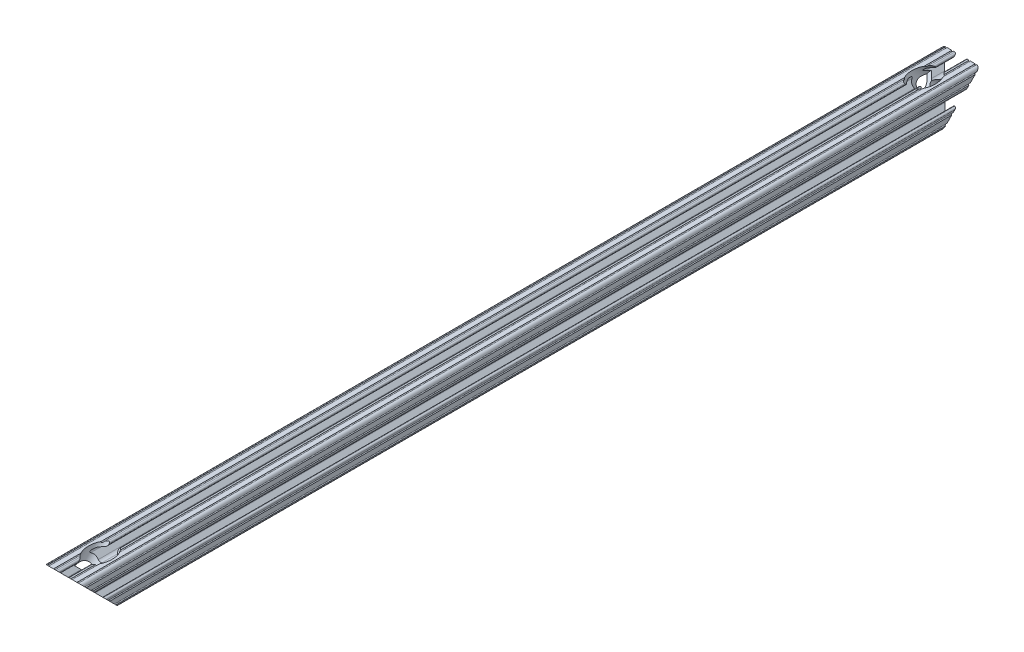
from build123d import *

# Parameters (mm, degrees)
SKETCH1_R               = 2.6035
BOSS_EXTRUDE1_DEPTH     = 304.8
CUT_EXTRUDE1_DEPTH      = 13.7
CUT_EXTRUDE1_DEPTH_BACK = 13.7


with BuildPart() as part:
    # Sketch1 → Boss-Extrude1 (new body, symmetric)
    with BuildSketch(Plane.XY):
        with BuildLine():
            Line((-7.179650497, -8.645192506), (-3.952270251, -5.423690499))
            ThreePointArc((-3.952270251, -5.423690499), (-2.922936451, -4.736929036), (-1.709253557, -4.4958))
            Line((-1.709253557, -4.4958), (1.709253557, -4.4958))
            ThreePointArc((1.709253557, -4.4958), (2.922936451, -4.736929036), (3.952270251, -5.423690499))
            Line((3.952270251, -5.423690499), (7.179650497, -8.645192506))
            ThreePointArc((7.179650497, -8.645192506), (7.41473083, -9.822813117), (6.416408329, -10.4902))
            Line((6.416408329, -10.4902), (4.287512407, -10.4902))
            ThreePointArc((4.287512407, -10.4902), (3.54574862, -10.79744862), (3.2385, -11.539212407))
            Line((3.2385, -11.539212407), (3.2385, -11.650987593))
            ThreePointArc((3.2385, -11.650987593), (3.54574862, -12.39275138), (4.287512407, -12.7))
            Line((4.287512407, -12.7), (5.317126718, -12.7))
            ThreePointArc((5.317126718, -12.7), (5.825126718, -12.192), (6.333126718, -12.7))
            Line((6.333126718, -12.7), (9.550443118, -12.7))
            ThreePointArc((9.550443118, -12.7), (10.058366869, -12.192000006), (10.566443095, -12.699847501))
            ThreePointArc((10.566443095, -12.699847501), (12.082537762, -12.08250727), (12.699846982, -10.566399977))
            ThreePointArc((12.699846982, -10.566399977), (12.192000006, -10.058323491), (12.7, -9.5504))
            Line((12.7, -9.5504), (12.7, -6.3330836))
            ThreePointArc((12.7, -6.3330836), (12.192, -5.8250836), (12.7, -5.3170836))
            Line((12.7, -5.3170836), (12.7, -4.287469289))
            ThreePointArc((12.7, -4.287469289), (12.39275138, -3.545705502), (11.650987593, -3.238456882))
            Line((11.650987593, -3.238456882), (11.539212407, -3.238456882))
            ThreePointArc((11.539212407, -3.238456882), (10.79744862, -3.545705502), (10.4902, -4.287469289))
            Line((10.4902, -4.287469289), (10.4902, -6.402089023))
            ThreePointArc((10.4902, -6.402089023), (9.856505071, -7.351067942), (8.737131347, -7.129408934))
            Line((8.737131347, -7.129408934), (5.441005833, -3.840816462))
            ThreePointArc((5.441005833, -3.840816462), (4.750877967, -2.809883091), (4.5085, -1.593185507))
            Line((4.5085, -1.593185507), (4.5085, 1.593185507))
            ThreePointArc((4.5085, 1.593185507), (4.750877967, 2.809883091), (5.441005833, 3.840816462))
            Line((5.441005833, 3.840816462), (8.737131347, 7.129408934))
            ThreePointArc((8.737131347, 7.129408934), (9.856505071, 7.351067942), (10.4902, 6.402089023))
            Line((10.4902, 6.402089023), (10.4902, 4.287469289))
            ThreePointArc((10.4902, 4.287469289), (10.79744862, 3.545705502), (11.539212407, 3.238456882))
            Line((11.539212407, 3.238456882), (11.650987593, 3.238456882))
            ThreePointArc((11.650987593, 3.238456882), (12.39275138, 3.545705502), (12.7, 4.287469289))
            Line((12.7, 4.287469289), (12.7, 5.3170836))
            ThreePointArc((12.7, 5.3170836), (12.192, 5.8250836), (12.7, 6.3330836))
            Line((12.7, 6.3330836), (12.7, 9.5504))
            ThreePointArc((12.7, 9.5504), (12.192000006, 10.058323491), (12.699846982, 10.566399977))
            ThreePointArc((12.699846982, 10.566399977), (12.082537762, 12.08250727), (10.566443095, 12.699847501))
            ThreePointArc((10.566443095, 12.699847501), (10.058366869, 12.192000006), (9.550443118, 12.7))
            Line((9.550443118, 12.7), (6.333126718, 12.7))
            ThreePointArc((6.333126718, 12.7), (5.825126718, 12.192), (5.317126718, 12.7))
            Line((5.317126718, 12.7), (4.287512407, 12.7))
            ThreePointArc((4.287512407, 12.7), (3.54574862, 12.39275138), (3.2385, 11.650987593))
            Line((3.2385, 11.650987593), (3.2385, 11.539212407))
            ThreePointArc((3.2385, 11.539212407), (3.54574862, 10.79744862), (4.287512407, 10.4902))
            Line((4.287512407, 10.4902), (6.476788598, 10.4902))
            ThreePointArc((6.476788598, 10.4902), (7.432222385, 9.85140422), (7.207036008, 8.724370562))
            Line((7.207036008, 8.724370562), (3.898272566, 5.423169045))
            ThreePointArc((3.898272566, 5.423169045), (2.869120213, 4.736787962), (1.655778399, 4.4958))
            Line((1.655778399, 4.4958), (-1.655778399, 4.4958))
            ThreePointArc((-1.655778399, 4.4958), (-2.869120213, 4.736787962), (-3.898272566, 5.423169045))
            Line((-3.898272566, 5.423169045), (-7.207036008, 8.724370562))
            ThreePointArc((-7.207036008, 8.724370562), (-7.432222385, 9.85140422), (-6.476788598, 10.4902))
            Line((-6.476788598, 10.4902), (-4.287512407, 10.4902))
            ThreePointArc((-4.287512407, 10.4902), (-3.54574862, 10.79744862), (-3.2385, 11.539212407))
            Line((-3.2385, 11.539212407), (-3.2385, 11.650987593))
            ThreePointArc((-3.2385, 11.650987593), (-3.54574862, 12.39275138), (-4.287512407, 12.7))
            Line((-4.287512407, 12.7), (-5.317126718, 12.7))
            ThreePointArc((-5.317126718, 12.7), (-5.825126718, 12.192), (-6.333126718, 12.7))
            Line((-6.333126718, 12.7), (-9.550443118, 12.7))
            ThreePointArc((-9.550443118, 12.7), (-10.058366869, 12.192000006), (-10.566443095, 12.699847501))
            ThreePointArc((-10.566443095, 12.699847501), (-12.082537762, 12.08250727), (-12.699846982, 10.566399977))
            ThreePointArc((-12.699846982, 10.566399977), (-12.192000006, 10.058323491), (-12.7, 9.5504))
            Line((-12.7, 9.5504), (-12.7, 6.3330836))
            ThreePointArc((-12.7, 6.3330836), (-12.192, 5.8250836), (-12.7, 5.3170836))
            Line((-12.7, 5.3170836), (-12.7, 4.287469289))
            ThreePointArc((-12.7, 4.287469289), (-12.39275138, 3.545705502), (-11.650987593, 3.238456882))
            Line((-11.650987593, 3.238456882), (-11.539212407, 3.238456882))
            ThreePointArc((-11.539212407, 3.238456882), (-10.79744862, 3.545705502), (-10.4902, 4.287469289))
            Line((-10.4902, 4.287469289), (-10.4902, 6.402089023))
            ThreePointArc((-10.4902, 6.402089023), (-9.856505071, 7.351067942), (-8.737131347, 7.129408934))
            Line((-8.737131347, 7.129408934), (-5.441005833, 3.840816462))
            ThreePointArc((-5.441005833, 3.840816462), (-4.750877967, 2.809883091), (-4.5085, 1.593185507))
            Line((-4.5085, 1.593185507), (-4.5085, -1.593185507))
            ThreePointArc((-4.5085, -1.593185507), (-4.750877967, -2.809883091), (-5.441005833, -3.840816462))
            Line((-5.441005833, -3.840816462), (-8.737131347, -7.129408934))
            ThreePointArc((-8.737131347, -7.129408934), (-9.856505071, -7.351067942), (-10.4902, -6.402089023))
            Line((-10.4902, -6.402089023), (-10.4902, -4.287469289))
            ThreePointArc((-10.4902, -4.287469289), (-10.79744862, -3.545705502), (-11.539212407, -3.238456882))
            Line((-11.539212407, -3.238456882), (-11.650987593, -3.238456882))
            ThreePointArc((-11.650987593, -3.238456882), (-12.39275138, -3.545705502), (-12.7, -4.287469289))
            Line((-12.7, -4.287469289), (-12.7, -5.3170836))
            ThreePointArc((-12.7, -5.3170836), (-12.192, -5.8250836), (-12.7, -6.3330836))
            Line((-12.7, -6.3330836), (-12.7, -9.5504))
            ThreePointArc((-12.7, -9.5504), (-12.192000006, -10.058323491), (-12.699846982, -10.566399977))
            ThreePointArc((-12.699846982, -10.566399977), (-12.082537762, -12.08250727), (-10.566443095, -12.699847501))
            ThreePointArc((-10.566443095, -12.699847501), (-10.058366869, -12.192000006), (-9.550443118, -12.7))
            Line((-9.550443118, -12.7), (-6.333126718, -12.7))
            ThreePointArc((-6.333126718, -12.7), (-5.825126718, -12.192), (-5.317126718, -12.7))
            Line((-5.317126718, -12.7), (-4.287512407, -12.7))
            ThreePointArc((-4.287512407, -12.7), (-3.54574862, -12.39275138), (-3.2385, -11.650987593))
            Line((-3.2385, -11.650987593), (-3.2385, -11.539212407))
            ThreePointArc((-3.2385, -11.539212407), (-3.54574862, -10.79744862), (-4.287512407, -10.4902))
            Line((-4.287512407, -10.4902), (-6.416408329, -10.4902))
            ThreePointArc((-6.416408329, -10.4902), (-7.41473083, -9.822813117), (-7.179650497, -8.645192506))
        make_face()
        Circle(SKETCH1_R, mode=Mode.SUBTRACT)
    extrude(amount=BOSS_EXTRUDE1_DEPTH, both=True)

    # Sketch2 → Cut-Extrude1 (cut, two sides)
    with BuildSketch(Plane(origin=(0, 0, 0), x_dir=(0, 0, -1), z_dir=(1, 0, 0))) as cut_extrude1_sk:
        Polygon((-304.8, 12.699847501), (-304.8, -12.7), (-279.400152499, -12.7), align=None)
        Polygon((279.400152499, -12.7), (304.8, 12.699847501), (304.8, -12.7), align=None)
    extrude(amount=CUT_EXTRUDE1_DEPTH, mode=Mode.SUBTRACT)
    extrude(cut_extrude1_sk.sketch, amount=-CUT_EXTRUDE1_DEPTH_BACK, mode=Mode.SUBTRACT)

    # Sketch3 → Cut-Revolve1 (revolve, cut)
    with BuildSketch(Plane(origin=(0, 0, 0), x_dir=(0, 0, -1), z_dir=(1, 0, 0))):
        Polygon((-273.787644922, 18.312507577), (-292.100152499, 0), (-294.408078322, 2.307925823), (-289.917950261, 6.798053884), (-293.222684514, 10.102788136), (-279.400304998, 23.925167653), align=None)
    cut_revolve1 = revolve(axis=Axis((0, 0, 292.100152499), (0, -0.707106781, 0.707106781)), mode=Mode.SUBTRACT)

    # Mirror1: Cut-Revolve1 across plane
    add(cut_revolve1.mirror(Plane.XY), mode=Mode.SUBTRACT)


solid = part.part
